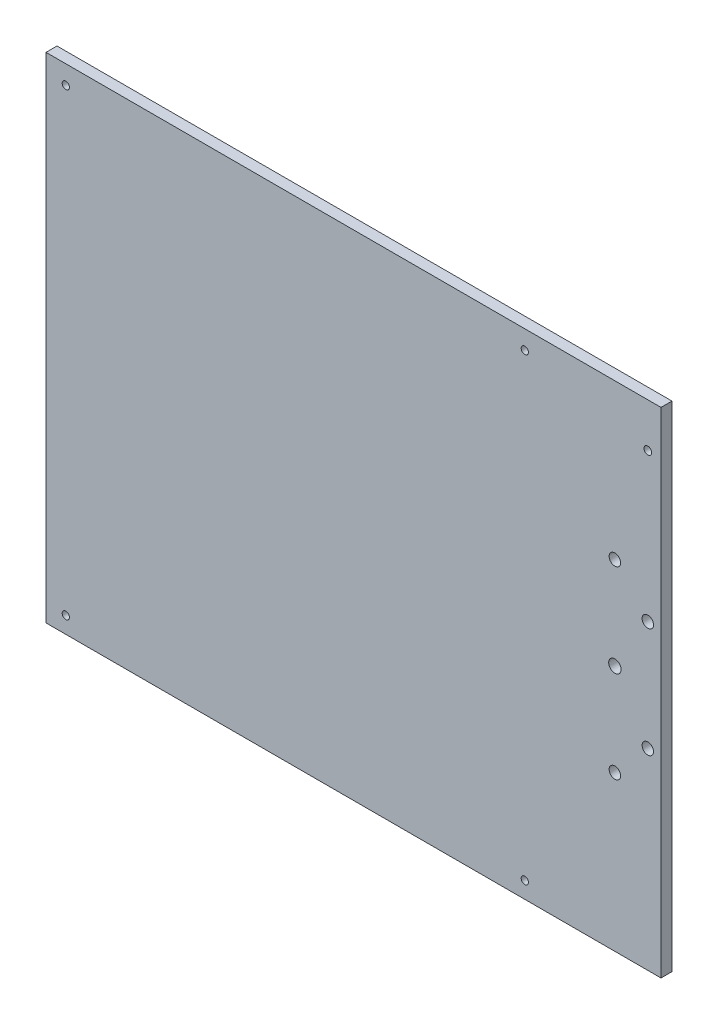
from build123d import *

# Parameters (mm, degrees)
SCHIZZO1_W                   = 280
SCHIZZO1_H                   = 225
ESTRUSIONE_ESTRUSIONE1_DEPTH = 5
FORO_FILETTATO_M4_1_D        = 3.3
FORO_FILETTATO_M4_1_DEPTH    = 5
SCHIZZO12_R                  = 2.6
SCHIZZO12_R_2                = 2.830640445
SCHIZZO12_R_3                = 1.75
TAGLIO_ESTRUSIONE1_DEPTH     = 10


with BuildPart() as part:
    # Schizzo1 → Estrusione-Estrusione1 (new body)
    with BuildSketch(Plane.XY):
        with Locations((-140, 132.5)):
            Rectangle(SCHIZZO1_W, SCHIZZO1_H)
    extrude(amount=ESTRUSIONE_ESTRUSIONE1_DEPTH)

    # Foro filettato M4-1
    with Locations(Plane(origin=(0, 0, 0), x_dir=(-1, 0, 0), z_dir=(0, 0, -1))):
        with Locations((271, 27.5), (62, 27.5), (271, 236.5), (62, 236.5)):
            Hole(FORO_FILETTATO_M4_1_D / 2, depth=FORO_FILETTATO_M4_1_DEPTH)

    # Schizzo12 → Taglio-Estrusione1 (cut)
    with BuildSketch(Plane(origin=(0, 0, 0), x_dir=(-1, 0, 0), z_dir=(0, 0, -1))):
        with Locations((6, 107.5)):
            Circle(SCHIZZO12_R)
        with Locations((6, 157.5)):
            Circle(SCHIZZO12_R)
        with Locations((21, 90.5)):
            Circle(SCHIZZO12_R)
        with Locations((21, 132.5)):
            Circle(SCHIZZO12_R_2)
        with Locations((21, 174.5)):
            Circle(SCHIZZO12_R)
        with Locations((6, 225)):
            Circle(SCHIZZO12_R_3)
    extrude(amount=-TAGLIO_ESTRUSIONE1_DEPTH, mode=Mode.SUBTRACT)


solid = part.part
